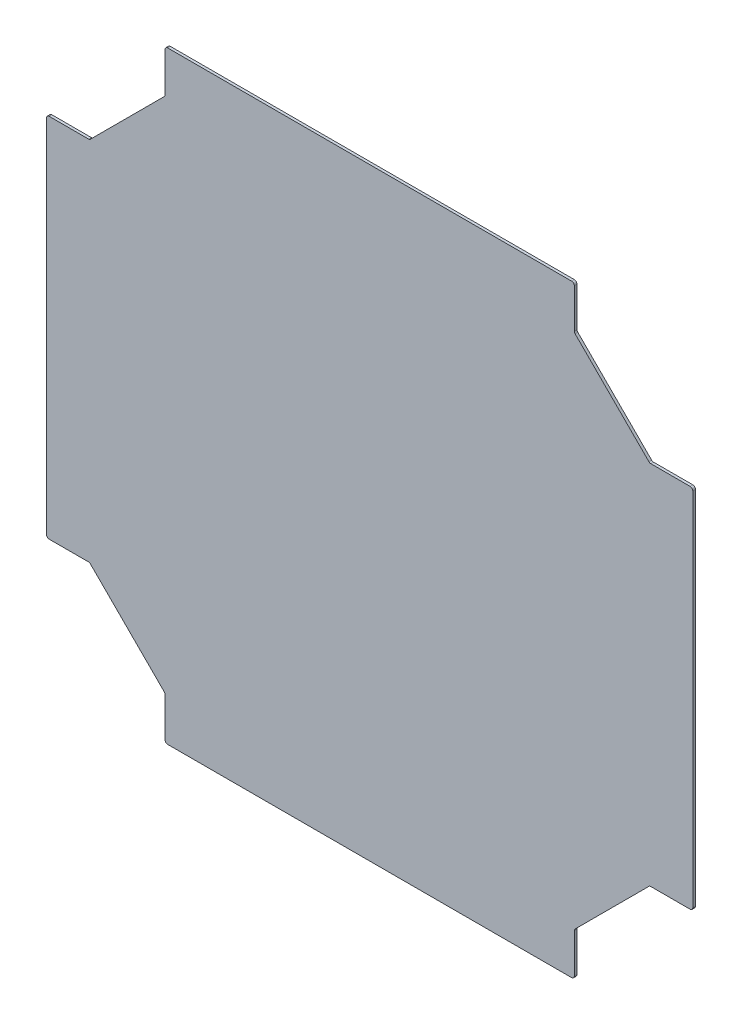
from build123d import *

# Parameters (mm, degrees)
SKETCH1_W           = 762
SKETCH1_H           = 711.2
BOSS_EXTRUDE1_DEPTH = 3.175
CUT_EXTRUDE1_DEPTH  = 4.175
FILLET1_R           = 3.175


with BuildPart() as part:
    # Sketch1 → Boss-Extrude1 (new body)
    with BuildSketch(Plane.XY):
        with Locations((381, 355.6)):
            Rectangle(SKETCH1_W, SKETCH1_H)
    extrude(amount=BOSS_EXTRUDE1_DEPTH)

    # Sketch2 → Cut-Extrude1 (cut, through all)
    with BuildSketch(Plane.XY.offset(3.175)):
        Polygon((0, 571.5), (50.8, 571.5), (139.7, 660.4), (139.7, 711.2), (0, 711.2), align=None)
        Polygon((139.7, 50.8), (139.7, 0), (0, 0), (0, 139.7), (50.8, 139.7), align=None)
        Polygon((762, 139.7), (711.2, 139.7), (622.3, 50.8), (622.3, 0), (762, 0), align=None)
        Polygon((622.3, 660.4), (622.3, 711.2), (762, 711.2), (762, 571.5), (711.2, 571.5), align=None)
    extrude(amount=-CUT_EXTRUDE1_DEPTH, mode=Mode.SUBTRACT)

    # Fillet1
    fillet1_edges = [part.edges().sort_by_distance(p)[0] for p in [
        (711.2, 571.5, 1.5875),
        (622.3, 660.4, 1.5875),
        (622.3, 711.2, 1.5875),
        (762, 571.5, 1.5875),
        (762, 139.7, 1.5875),
        (622.3, 0, 1.5875),
        (622.3, 50.8, 1.5875),
        (711.2, 139.7, 1.5875),
        (50.8, 139.7, 1.5875),
        (139.7, 50.8, 1.5875),
        (139.7, 0, 1.5875),
        (0, 139.7, 1.5875),
        (0, 571.5, 1.5875),
        (139.7, 711.2, 1.5875),
        (139.7, 660.4, 1.5875),
        (50.8, 571.5, 1.5875),
    ]]
    fillet(fillet1_edges, radius=FILLET1_R)


solid = part.part
